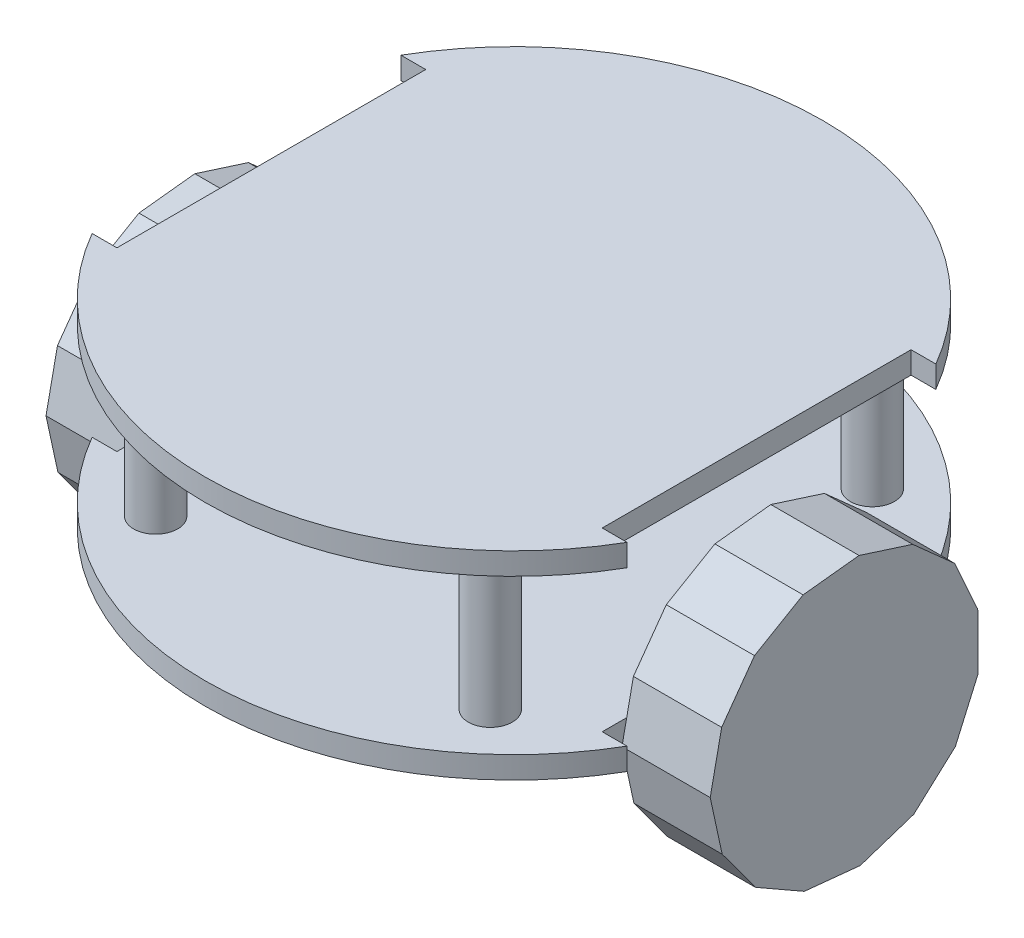
from build123d import *

# Parameters (mm, degrees)
BOSS_EXTRUDE2_DEPTH = 5
SKETCH7_R           = 5
BOSS_EXTRUDE3_DEPTH = 40
BOSS_EXTRUDE5_DEPTH = 5
BOSS_EXTRUDE7_DEPTH = 20
BOSS_EXTRUDE8_DEPTH = 20


with BuildPart() as part:
    # Sketch2 → Boss-Extrude2 (new body)
    with BuildSketch(Plane(origin=(0, 0, 0), x_dir=(1, 0, 0), z_dir=(0, 1, 0))):
        with BuildLine():
            ThreePointArc((-11.424183933, 41.384676223), (49.197594332, 6.384676223), (109.819372597, 41.384676223))
            Line((109.819372597, 41.384676223), (104.197594332, 41.384676223))
            Line((104.197594332, 41.384676223), (104.197594332, 111.384676223))
            Line((104.197594332, 111.384676223), (109.819372597, 111.384676223))
            ThreePointArc((109.819372597, 111.384676223), (49.197594332, 146.384676223), (-11.424183933, 111.384676223))
            Line((-11.424183933, 111.384676223), (-5.802405668, 111.384676223))
            Line((-5.802405668, 111.384676223), (-5.802405668, 41.384676223))
            Line((-5.802405668, 41.384676223), (-11.424183933, 41.384676223))
        make_face()
    extrude(amount=BOSS_EXTRUDE2_DEPTH)

    # Sketch7 → Boss-Extrude3 (add)
    with BuildSketch(Plane(origin=(0, 0, 0), x_dir=(1, 0, 0), z_dir=(0, 1, 0))):
        with Locations((11.270866676, 119.685946413)):
            Circle(SKETCH7_R)
        with Locations((87.124321988, 119.685946413)):
            Circle(SKETCH7_R)
        with Locations((87.124321988, 33.083406034)):
            Circle(SKETCH7_R)
        with Locations((11.270866676, 33.083406034)):
            Circle(SKETCH7_R)
    extrude(amount=BOSS_EXTRUDE3_DEPTH)

    # Sketch12 → Boss-Extrude5 (add)
    with BuildSketch(Plane(origin=(0, 40, 0), x_dir=(1, 0, 0), z_dir=(0, 1, 0))):
        with BuildLine():
            Line((109.819372597, 41.384676223), (104.197594332, 41.384676223))
            Line((104.197594332, 41.384676223), (104.197594332, 111.384676223))
            Line((104.197594332, 111.384676223), (109.819372597, 111.384676223))
            ThreePointArc((109.819372597, 111.384676223), (49.197594332, 146.384676223), (-11.424183933, 111.384676223))
            Line((-11.424183933, 111.384676223), (-5.802405668, 111.384676223))
            Line((-5.802405668, 111.384676223), (-5.802405668, 41.384676223))
            Line((-5.802405668, 41.384676223), (-11.424183933, 41.384676223))
            ThreePointArc((-11.424183933, 41.384676223), (49.197594332, 6.384676223), (109.819372597, 41.384676223))
        make_face()
    extrude(amount=BOSS_EXTRUDE5_DEPTH)


with BuildPart() as body_2:
    # Sketch15 → Boss-Extrude7 (new body)
    with BuildSketch(Plane.ZY.offset(6)):
        Polygon((-48.215080274, -12.60049092), (-45.507466236, -0.137831609), (-48.102957942, 12.348660039), (-55.552771297, 22.699956182), (-66.568765893, 29.126223679), (-79.246176186, 30.516302498), (-91.392962767, 26.629835384), (-100.908835886, 18.138827807), (-106.14841463, 6.511452116), (-106.205728236, -6.2418128), (-101.07086666, -17.915811578), (-91.631694118, -26.492003774), (-79.520329293, -30.487487845), (-66.830937194, -29.211408298), (-55.757628992, -22.884410879), align=None)
    extrude(amount=BOSS_EXTRUDE7_DEPTH)


with BuildPart() as body_3:
    # Sketch18 → Boss-Extrude8 (new body)
    with BuildSketch(Plane.ZY.offset(-104.2)):
        Polygon((-48.567110562, -12.614898246), (-45.859496523, -0.152238936), (-48.454988229, 12.334252712), (-55.904801584, 22.685548856), (-66.92079618, 29.111816352), (-79.598206473, 30.501895172), (-91.744993054, 26.615428057), (-101.260866173, 18.124420481), (-106.500444917, 6.49704479), (-106.557758523, -6.256220126), (-101.422896947, -17.930218904), (-91.983724405, -26.5064111), (-79.87235958, -30.501895172), (-67.182967481, -29.225815624), (-56.109659279, -22.898818205), align=None)
    extrude(amount=-BOSS_EXTRUDE8_DEPTH)


solid = Compound([part.part, body_2.part, body_3.part])
